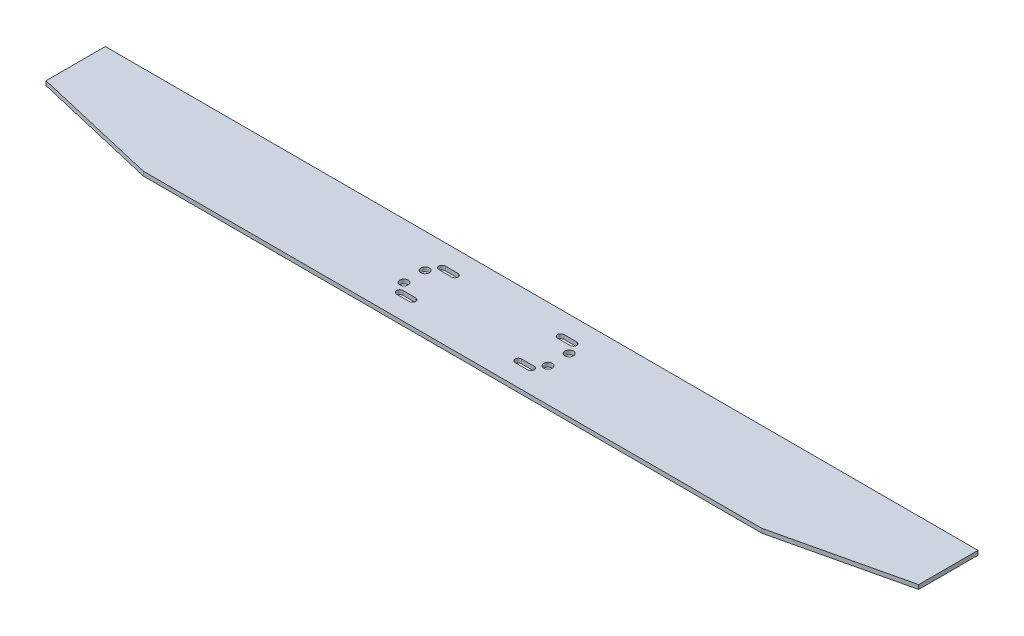
from build123d import *

# Parameters (mm, degrees)
EXTRUDE_1_DEPTH     = 0.5
SKETCH_2_R          = 1
SKETCH_2_W          = 3
SKETCH_2_H          = 1.5
CUT_EXTRUDE_1_DEPTH = 2
SKETCH_3_R          = 0.75
CUT_EXTRUDE_2_DEPTH = 2


with BuildPart() as part:
    # 草图1 → 凸台-拉伸1 (new body, symmetric)
    with BuildSketch(Plane(origin=(0, 0, 0), x_dir=(1, 0, 0), z_dir=(0, 1, 0))):
        Polygon((103, 0), (-103, 0), (-103, -14), (-73, -21), (73, -21), (103, -14), align=None)
    extrude(amount=EXTRUDE_1_DEPTH, both=True)

    # 草图2 → 切除-拉伸1 (cut, through all)
    with BuildSketch(Plane(origin=(0, 0.5, 0), x_dir=(1, 0, 0), z_dir=(0, 1, 0))):
        with Locations((14.5, -13)):
            Circle(SKETCH_2_R)
        with Locations((14.5, -8)):
            Circle(SKETCH_2_R)
        with Locations((-19.5, -8)):
            Circle(SKETCH_2_R)
        with Locations((-19.5, -13)):
            Circle(SKETCH_2_R)
        with Locations((11.5, -5.5)):
            Rectangle(SKETCH_2_W, SKETCH_2_H)
        with Locations((11.5, -15.5)):
            Rectangle(SKETCH_2_W, SKETCH_2_H)
        with Locations((-16.5, -15.5)):
            Rectangle(SKETCH_2_W, SKETCH_2_H)
        with Locations((-16.5, -5.5)):
            Rectangle(SKETCH_2_W, SKETCH_2_H)
    extrude(amount=-CUT_EXTRUDE_1_DEPTH, mode=Mode.SUBTRACT)

    # 草图3 → 切除-拉伸2 (cut, through all)
    with BuildSketch(Plane(origin=(0, 0.5, 0), x_dir=(1, 0, 0), z_dir=(0, 1, 0))):
        with Locations((-18, -5.5)):
            Circle(SKETCH_3_R)
        with Locations((-15, -5.5)):
            Circle(SKETCH_3_R)
        with Locations((-18, -15.5)):
            Circle(SKETCH_3_R)
        with Locations((-15, -15.5)):
            Circle(SKETCH_3_R)
        with Locations((10, -5.5)):
            Circle(SKETCH_3_R)
        with Locations((10, -15.5)):
            Circle(SKETCH_3_R)
        with Locations((13, -15.5)):
            Circle(SKETCH_3_R)
        with Locations((13, -5.5)):
            Circle(SKETCH_3_R)
    extrude(amount=-CUT_EXTRUDE_2_DEPTH, mode=Mode.SUBTRACT)


solid = part.part
